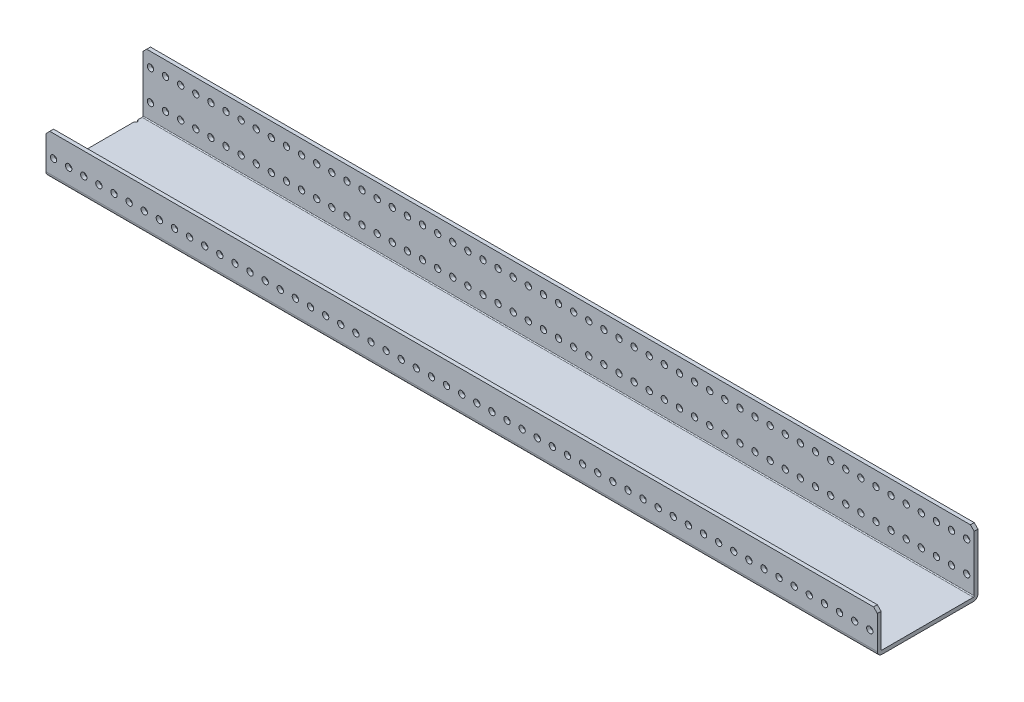
from build123d import *

# Parameters (mm, degrees)
SKETCH1_W            = 698.5
SKETCH1_H            = 84.582
BOSS_EXTRUDE1_DEPTH  = 34.925
SKETCH2_W            = 81.407
SKETCH2_H            = 31.75
CUT_EXTRUDE1_DEPTH   = 699.5
SKETCH3_W            = 698.5
SKETCH3_H            = 3.175
BOSS_EXTRUDE2_DEPTH  = 50.8
M2_CLEARANCE_HOLE1_D = 2.54
M5_CLEARANCE_HOLE1_D = 5.334
CHAMFER1_SIZE        = 3.175
FILLET1_R            = 0.762
FILLET2_R            = 3.937


with BuildPart() as part:
    # Sketch1 → Boss-Extrude1 (new body)
    with BuildSketch(Plane(origin=(0, 57.816398039, 0), x_dir=(1, 0, 0), z_dir=(0, 1, 0))):
        with Locations((253.148031467, -103.269491579)):
            Rectangle(SKETCH1_W, SKETCH1_H)
    extrude(amount=-BOSS_EXTRUDE1_DEPTH)

    # Sketch2 → Cut-Extrude1 (cut, through all)
    with BuildSketch(Plane(origin=(602.398031467, 0, 0), x_dir=(0, 0, -1), z_dir=(1, 0, 0))):
        with Locations((-101.681991579, 41.941398039)):
            Rectangle(SKETCH2_W, SKETCH2_H)
    extrude(amount=-CUT_EXTRUDE1_DEPTH, mode=Mode.SUBTRACT)

    # Sketch3 → Boss-Extrude2 (add)
    with BuildSketch(Plane(origin=(0, 26.066398039, 0), x_dir=(-1, 0, 0), z_dir=(0, 1, 0))):
        with Locations((-253.148031467, 62.565991579)):
            Rectangle(SKETCH3_W, SKETCH3_H)
    extrude(amount=BOSS_EXTRUDE2_DEPTH)

    # M2 Clearance Hole1 (through all)
    with Locations(Plane(origin=(0, 26.066398039, 0), x_dir=(1, 0, 0), z_dir=(0, 1, 0))):
        with Locations((-96.101968533, -136.543491579), (-96.101968533, -69.995491579)):
            Hole(M2_CLEARANCE_HOLE1_D / 2)

    # M5 Clearance Hole1 (through all)
    with Locations(Plane(origin=(0, 0, 60.978491579), x_dir=(-1, 0, 0), z_dir=(0, 0, -1))):
        with Locations((-469.048031467, 64.928398039), (-481.748031467, 64.928398039), (-469.048031467, 39.528398039), (-481.748031467, 39.528398039), (-456.348031467, 39.528398039), (-443.648031467, 39.528398039), (-430.948031467, 39.528398039), (-418.248031467, 39.528398039), (-405.548031467, 39.528398039), (-392.848031467, 39.528398039), (-380.148031467, 39.528398039), (-367.448031467, 39.528398039), (-354.748031467, 39.528398039), (-342.048031467, 39.528398039), (-329.348031467, 39.528398039), (-316.648031467, 39.528398039), (-303.948031467, 39.528398039), (-291.248031467, 39.528398039), (-278.548031467, 39.528398039), (-265.848031467, 39.528398039), (-253.148031467, 39.528398039), (-240.448031467, 39.528398039), (-227.748031467, 39.528398039), (-215.048031467, 39.528398039), (-202.348031467, 39.528398039), (-189.648031467, 39.528398039), (-176.948031467, 39.528398039), (-164.248031467, 39.528398039), (-151.548031467, 39.528398039), (-138.848031467, 39.528398039), (-126.148031467, 39.528398039), (-113.448031467, 39.528398039), (-100.748031467, 39.528398039), (-88.048031467, 39.528398039), (-75.348031467, 39.528398039), (-62.648031467, 39.528398039), (-49.948031467, 39.528398039), (-37.248031467, 39.528398039), (-24.548031467, 39.528398039), (-11.848031467, 39.528398039), (0.851968533, 39.528398039), (13.551968533, 39.528398039), (26.251968533, 39.528398039), (38.951968533, 39.528398039), (51.651968533, 39.528398039), (64.351968533, 39.528398039), (77.051968533, 39.528398039), (89.751968533, 39.528398039), (-456.348031467, 64.928398039), (-443.648031467, 64.928398039), (-430.948031467, 64.928398039), (-418.248031467, 64.928398039), (-405.548031467, 64.928398039), (-392.848031467, 64.928398039), (-380.148031467, 64.928398039), (-367.448031467, 64.928398039), (-354.748031467, 64.928398039), (-342.048031467, 64.928398039), (-329.348031467, 64.928398039), (-316.648031467, 64.928398039), (-303.948031467, 64.928398039), (-291.248031467, 64.928398039), (-278.548031467, 64.928398039), (-265.848031467, 64.928398039), (-253.148031467, 64.928398039), (-240.448031467, 64.928398039), (-227.748031467, 64.928398039), (-215.048031467, 64.928398039), (-202.348031467, 64.928398039), (-189.648031467, 64.928398039), (-176.948031467, 64.928398039), (-164.248031467, 64.928398039), (-151.548031467, 64.928398039), (-138.848031467, 64.928398039), (-126.148031467, 64.928398039), (-113.448031467, 64.928398039), (-100.748031467, 64.928398039), (-88.048031467, 64.928398039), (-75.348031467, 64.928398039), (-62.648031467, 64.928398039), (-49.948031467, 64.928398039), (-37.248031467, 64.928398039), (-24.548031467, 64.928398039), (-11.848031467, 64.928398039), (0.851968533, 64.928398039), (13.551968533, 64.928398039), (26.251968533, 64.928398039), (38.951968533, 64.928398039), (51.651968533, 64.928398039), (64.351968533, 64.928398039), (77.051968533, 64.928398039), (89.751968533, 64.928398039), (-494.448031467, 64.928398039), (-494.448031467, 39.528398039), (-507.148031467, 64.928398039), (-507.148031467, 39.528398039), (-519.848031467, 64.928398039), (-519.848031467, 39.528398039), (-532.548031467, 64.928398039), (-532.548031467, 39.528398039), (-545.248031467, 64.928398039), (-545.248031467, 39.528398039), (-557.948031467, 64.928398039), (-557.948031467, 39.528398039), (-570.648031467, 64.928398039), (-570.648031467, 39.528398039), (-583.348031467, 64.928398039), (-583.348031467, 39.528398039), (-596.048031467, 64.928398039), (-596.048031467, 39.528398039)):
            Hole(M5_CLEARANCE_HOLE1_D / 2)

    # Chamfer1
    chamfer1_edges = [part.edges().sort_by_distance(p)[0] for p in [
        (-96.101968533, 57.816398039, 143.972991579),
        (-96.101968533, 76.866398039, 62.565991579),
        (602.398031467, 76.866398039, 62.565991579),
        (602.398031467, 57.816398039, 143.972991579),
    ]]
    chamfer(chamfer1_edges, length=CHAMFER1_SIZE)

    # Fillet1
    fillet1_edges = [part.edges().sort_by_distance(p)[0] for p in [
        (253.148031467, 26.066398039, 142.385491579),
        (253.148031467, 26.066398039, 64.153491579),
    ]]
    fillet(fillet1_edges, radius=FILLET1_R)

    # Fillet2
    fillet2_edges = [part.edges().sort_by_distance(p)[0] for p in [
        (253.148031467, 22.891398039, 60.978491579),
        (253.148031467, 22.891398039, 145.560491579),
    ]]
    fillet(fillet2_edges, radius=FILLET2_R)


solid = part.part
